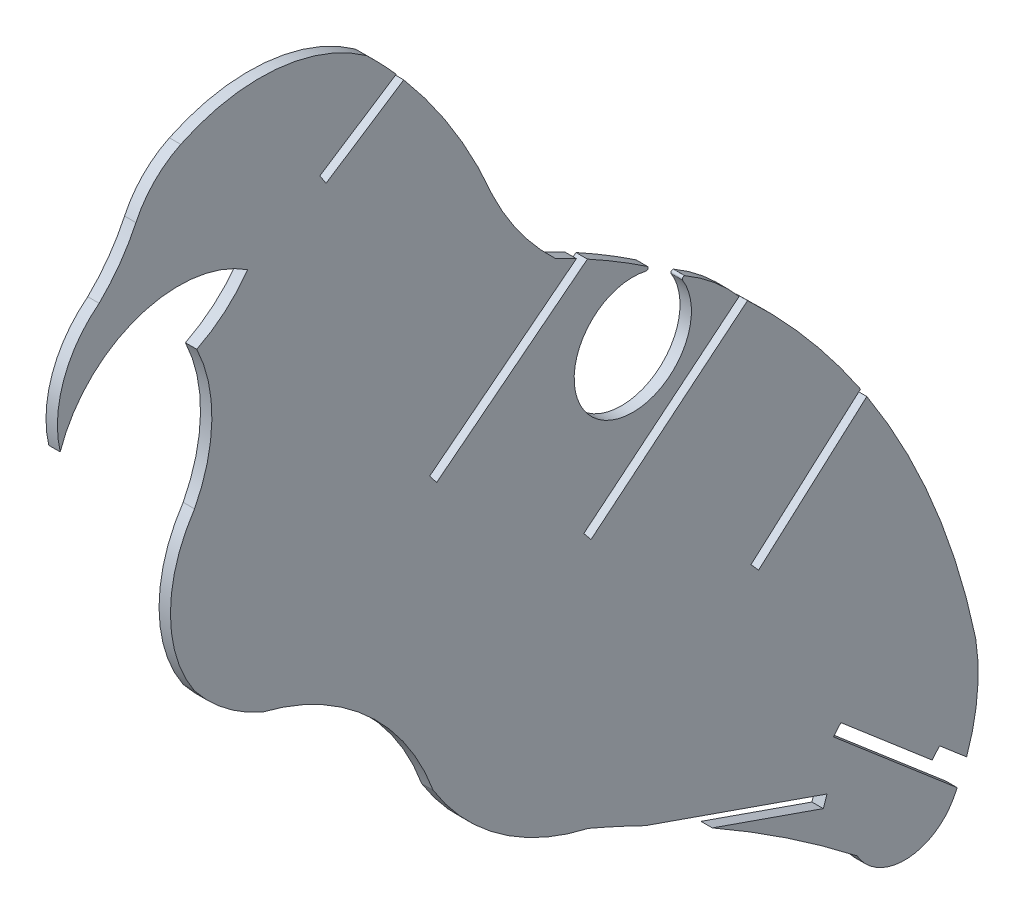
from build123d import *

# Parameters (mm, degrees)
BOSS_EXTRUDE1_DEPTH = 1.524


with BuildPart() as part:
    # Sketch1 → Boss-Extrude1 (new body)
    with BuildSketch(Plane(origin=(0, 0, 0), x_dir=(0, 0, -1), z_dir=(1, 0, 0))):
        with BuildLine():
            Line((13.407652518, 17.110478898), (3.184449025, 10.435661085))
            Line((3.184449025, 10.435661085), (4.017618802, 9.159571698))
            Line((4.017618802, 9.159571698), (14.415583003, 15.948492286))
            ThreePointArc((14.415583003, 15.948492286), (21.092922372, 6.750259445), (26.29476658, -3.355934957))
            ThreePointArc((26.29476658, -3.355934957), (29.972883945, -9.528005236), (34.723111664, -14.918583638))
            ThreePointArc((34.723111664, -14.918583638), (36.135111524, -15.61884561), (37.536333073, -16.340433168))
            Line((37.536333073, -16.340433168), (17.883159134, -31.731702551))
            Line((17.883159134, -31.731702551), (18.82281135, -32.931548254))
            Line((18.82281135, -32.931548254), (39.005018059, -17.125969921))
            ThreePointArc((39.005018059, -17.125969921), (43.071954568, -19.463822973), (47.029287435, -21.982760456))
            ThreePointArc((47.029287435, -21.982760456), (47.121340823, -22.294468188), (46.831491474, -22.44151543))
            ThreePointArc((46.831491474, -22.44151543), (40.524268055, -36.485757729), (51.747180655, -25.946875351))
            ThreePointArc((51.747180655, -25.946875351), (51.79176687, -25.624931868), (52.116458195, -25.610403262))
            ThreePointArc((52.116458195, -25.610403262), (55.970170844, -28.311608841), (59.322656596, -31.614403422))
            Line((59.322656596, -31.614403422), (38.521293058, -48.704406988))
            Line((38.521293058, -48.704406988), (39.48874306, -49.8819538))
            Line((39.48874306, -49.8819538), (60.451087926, -32.659691044))
            ThreePointArc((60.451087926, -32.659691044), (65.449164438, -37.690671834), (70.092626303, -43.050690343))
            ThreePointArc((70.092626303, -43.050690343), (72.914169877, -46.704495979), (75.570723168, -50.479959972))
            Line((75.570723168, -50.479959972), (60.910405453, -63.506128463))
            Line((60.910405453, -63.506128463), (61.922669103, -64.64538186))
            Line((61.922669103, -64.64538186), (76.419081079, -51.764848943))
            ThreePointArc((76.419081079, -51.764848943), (85.346593392, -68.759689082), (90.997112415, -87.10626103))
            ThreePointArc((90.997112415, -87.10626103), (91.213266354, -93.748148771), (89.779086784, -100.23694868))
            Line((89.779086784, -100.23694868), (86.156676546, -97.139104436))
            Line((86.156676546, -97.139104436), (85.16617589, -98.297329135))
            Line((85.16617589, -98.297329135), (72.942235832, -87.843553926))
            Line((72.942235832, -87.843553926), (71.951735177, -89.001778624))
            Line((71.951735177, -89.001778624), (88.527211746, -103.176938614))
            ThreePointArc((88.527211746, -103.176938614), (88.240593298, -103.735184094), (87.940907668, -104.286524891))
            ThreePointArc((87.940907668, -104.286524891), (81.546731579, -108.065445103), (75.104666757, -104.368753791))
            ThreePointArc((75.104666757, -104.368753791), (65.647792617, -97.564665833), (55.732787106, -91.447415868))
            Line((55.732787106, -91.447415868), (70.587569953, -96.632218566))
            Line((70.587569953, -96.632218566), (71.089783687, -95.193344922))
            Line((71.089783687, -95.193344922), (46.757147713, -86.700463003))
            ThreePointArc((46.757147713, -86.700463003), (46.008174549, -86.335839826), (45.257363435, -85.975016415))
            ThreePointArc((45.257363435, -85.975016415), (42.216480057, -84.561010059), (39.14738639, -83.209326015))
            ThreePointArc((39.14738639, -83.209326015), (27.255727661, -77.897933177), (18.352985242, -68.39195513))
            ThreePointArc((18.352985242, -68.39195513), (9.477657224, -55.283796186), (-4.522491883, -47.89521694))
            ThreePointArc((-4.522491883, -47.89521694), (-9.486665924, -44.951872039), (-13.595983785, -40.899735587))
            ThreePointArc((-13.595983785, -40.899735587), (-16.824505318, -30.34398814), (-13.595983785, -19.788240693))
            ThreePointArc((-13.595983785, -19.788240693), (-11.273947375, -10.645865952), (-13.295774557, -1.432447268))
            ThreePointArc((-13.295774557, -1.432447268), (-9.527302248, 1.055622975), (-6.46891992, 4.377997821))
            ThreePointArc((-6.46891992, 4.377997821), (-21.126971598, 6.251882407), (-31.581931465, -4.191476087))
            ThreePointArc((-31.581931465, -4.191476087), (-31.126828301, 3.888628011), (-26.369564479, 10.435661085))
            ThreePointArc((-26.369564479, 10.435661085), (-23.587438274, 13.654628259), (-21.440611016, 17.327924955))
            ThreePointArc((-21.440611016, 17.327924955), (-18.964873682, 20.882521181), (-15.438488132, 23.398278447))
            ThreePointArc((-15.438488132, 23.398278447), (-2.701283032, 25.730330795), (9.447763641, 21.249758643))
            ThreePointArc((9.447763641, 21.249758643), (11.467468523, 19.218156049), (13.407652518, 17.110478898))
        make_face()
    extrude(amount=BOSS_EXTRUDE1_DEPTH)


solid = part.part
